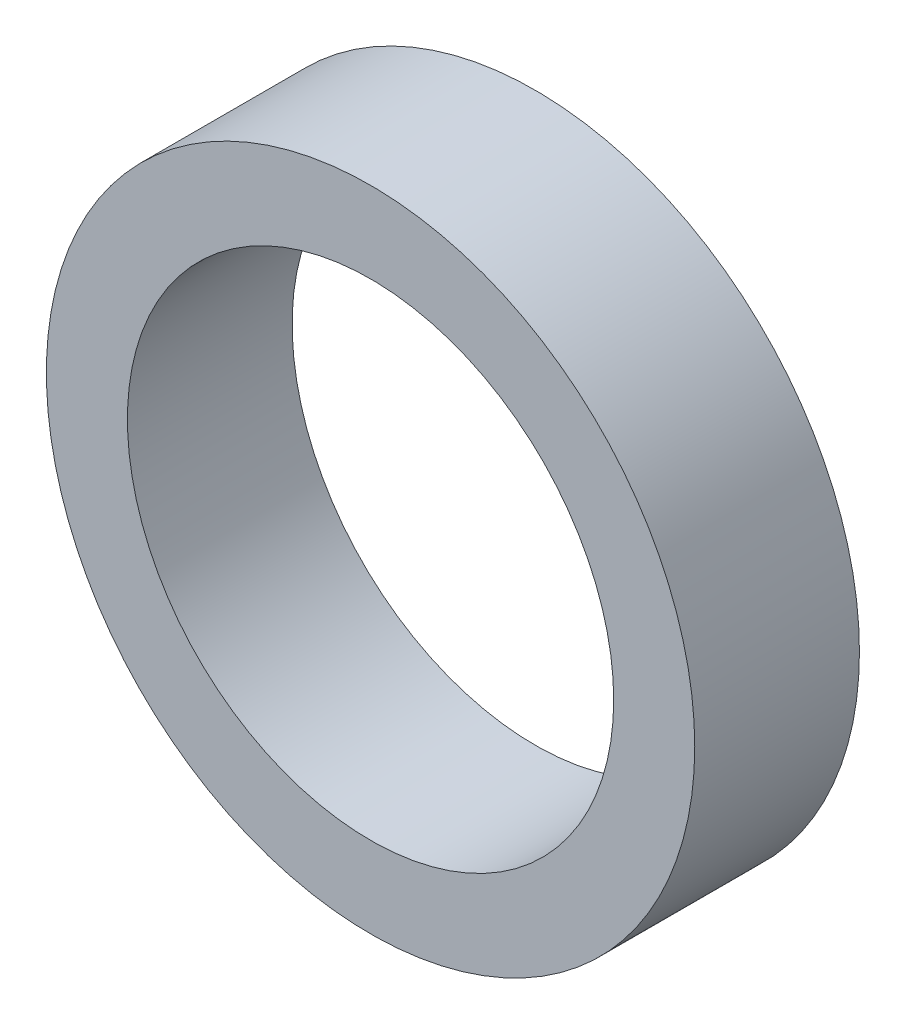
from build123d import *

# Parameters (mm, degrees)
SKETCH1_R      = 2
SKETCH1_R_2    = 1.5
EXTRUDE1_DEPTH = 1.016


with BuildPart() as part:
    # Sketch1 → Extrude1 (new body)
    with BuildSketch(Plane.XY):
        Circle(SKETCH1_R)
        Circle(SKETCH1_R_2, mode=Mode.SUBTRACT)
    extrude(amount=EXTRUDE1_DEPTH)


solid = part.part
